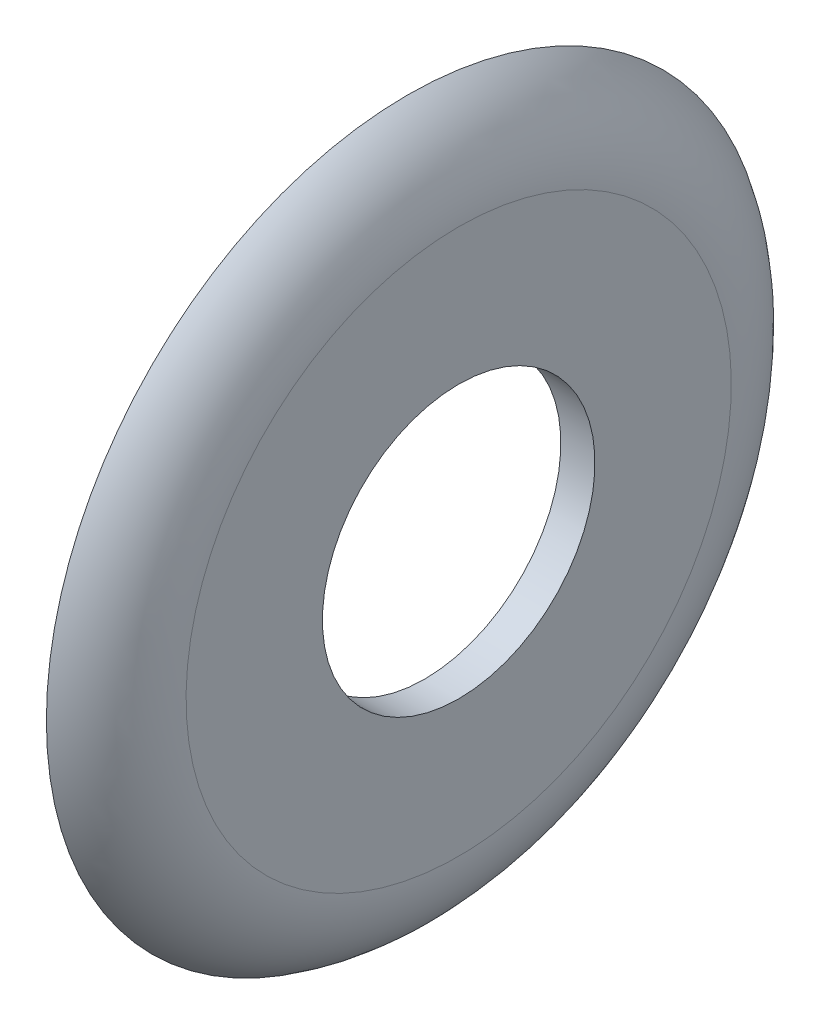
from build123d import *


with BuildPart() as part:
    # Sketch2 → Revolve1 (revolve)
    with BuildSketch(Plane.XY):
        with BuildLine():
            Line((4.479648978, 7.99509787), (6.479648978, 7.99509787))
            Line((6.479648978, 7.99509787), (6.479648978, 15.99509787))
            ThreePointArc((6.479648978, 15.99509787), (5.675801401, 18.99509787), (3.479648978, 21.191250292))
            Line((3.479648978, 21.191250292), (3.479648978, 19.31172266))
            ThreePointArc((3.479648978, 19.31172266), (4.224211625, 17.727148677), (4.479648978, 15.99509787))
            Line((4.479648978, 15.99509787), (4.479648978, 7.99509787))
        make_face()
    revolve(axis=Axis((6.479648978, 0, 0), (-1, 0, 0)))


solid = part.part
